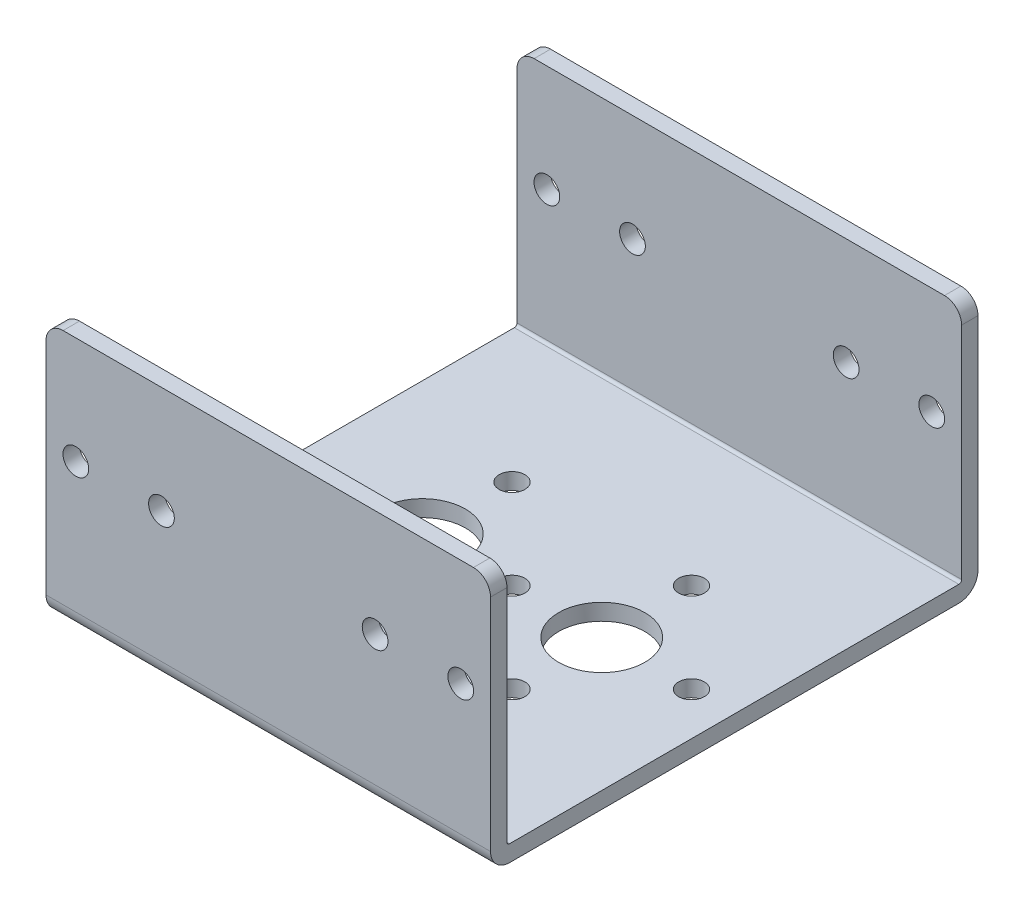
from build123d import *

# Parameters (mm, degrees)
EXTRUDE1_DEPTH          = 20.6375
EXTRUDE1_DEPTH_BACK     = 20.6375
SKETCH2_R               = 4.0005
SKETCH2_R_2             = 1.1938
CUT_EXTRUDE1_DEPTH      = 20.6375
CUT_EXTRUDE1_DEPTH_BACK = 20.6375
SKETCH3_R               = 1.1938
CUT_EXTRUDE2_DEPTH      = 23.62886
CUT_EXTRUDE2_DEPTH_BACK = 23.62886
FILLET1_R               = 1.5875


with BuildPart() as part:
    # Sketch1 → Extrude1 (new body, two sides)
    with BuildSketch(Plane(origin=(0, 0, 0), x_dir=(0, 0, -1), z_dir=(1, 0, 0))) as extrude1_sk:
        with BuildLine():
            Line((-20.85086, 0), (20.85086, 0))
            ThreePointArc((20.85086, 0), (22.108095857, 0.520764143), (22.62886, 1.778))
            Line((22.62886, 1.778), (22.62886, 23.8252))
            Line((22.62886, 23.8252), (21.10486, 23.8252))
            Line((21.10486, 23.8252), (21.10486, 1.778))
            ThreePointArc((21.10486, 1.778), (21.030465122, 1.598394878), (20.85086, 1.524))
            Line((20.85086, 1.524), (-20.85086, 1.524))
            ThreePointArc((-20.85086, 1.524), (-21.030465122, 1.598394878), (-21.10486, 1.778))
            Line((-21.10486, 1.778), (-21.10486, 23.8252))
            Line((-21.10486, 23.8252), (-22.62886, 23.8252))
            Line((-22.62886, 23.8252), (-22.62886, 1.778))
            ThreePointArc((-22.62886, 1.778), (-22.108095857, 0.520764143), (-20.85086, 0))
        make_face()
    extrude(amount=EXTRUDE1_DEPTH)
    extrude(extrude1_sk.sketch, amount=-EXTRUDE1_DEPTH_BACK)

    # Sketch2 → Cut-Extrude1 (cut, two sides)
    with BuildSketch(Plane(origin=(0, 0, 0), x_dir=(1, 0, 0), z_dir=(0, 1, 0))) as cut_extrude1_sk:
        with Locations(Location((-8.3312, 0, 0), (0, 0, 270))):  # turned: the seam where the file's is
            Circle(SKETCH2_R)
        with Locations(Location((8.3312, 0, 0), (0, 0, 270))):  # turned: the seam where the file's is
            Circle(SKETCH2_R)
        with Locations(Location((16.6624, 0, 0), (0, 0, 270))):  # turned: the seam where the file's is
            Circle(SKETCH2_R_2)
        with Locations(Location((-16.6624, 0, 0), (0, 0, 270))):  # turned: the seam where the file's is
            Circle(SKETCH2_R_2)
        with Locations(Location((-8.3312, 8.3312, 0), (0, 0, 270))):  # turned: the seam where the file's is
            Circle(SKETCH2_R_2)
        with Locations(Location((8.3312, 8.3312, 0), (0, 0, 270))):  # turned: the seam where the file's is
            Circle(SKETCH2_R_2)
        with Locations(Location((-8.3312, -8.3312, 0), (0, 0, 270))):  # turned: the seam where the file's is
            Circle(SKETCH2_R_2)
        with Locations(Location((8.3312, -8.3312, 0), (0, 0, 270))):  # turned: the seam where the file's is
            Circle(SKETCH2_R_2)
        with Locations(Location((0, 0, 0), (0, 0, 270))):  # turned: the seam where the file's is
            Circle(SKETCH2_R_2)
    extrude(amount=CUT_EXTRUDE1_DEPTH, mode=Mode.SUBTRACT)
    extrude(cut_extrude1_sk.sketch, amount=-CUT_EXTRUDE1_DEPTH_BACK, mode=Mode.SUBTRACT)

    # Sketch3 → Cut-Extrude2 (cut, two sides)
    with BuildSketch(Plane.XY) as cut_extrude2_sk:
        with Locations((-17.8689, 13.8938)):
            Circle(SKETCH3_R)
        with Locations((-9.9187, 13.8938)):
            Circle(SKETCH3_R)
        with Locations((9.9187, 13.8938)):
            Circle(SKETCH3_R)
        with Locations((17.8689, 13.8938)):
            Circle(SKETCH3_R)
    extrude(amount=CUT_EXTRUDE2_DEPTH, mode=Mode.SUBTRACT)
    extrude(cut_extrude2_sk.sketch, amount=-CUT_EXTRUDE2_DEPTH_BACK, mode=Mode.SUBTRACT)

    # Fillet1
    fillet1_edges = [part.edges().sort_by_distance(p)[0] for p in [
        (20.6375, 23.8252, -21.86686),
        (-20.6375, 23.8252, 21.86686),
        (-20.6375, 23.8252, -21.86686),
        (20.6375, 23.8252, 21.86686),
    ]]
    fillet(fillet1_edges, radius=FILLET1_R)


solid = part.part
